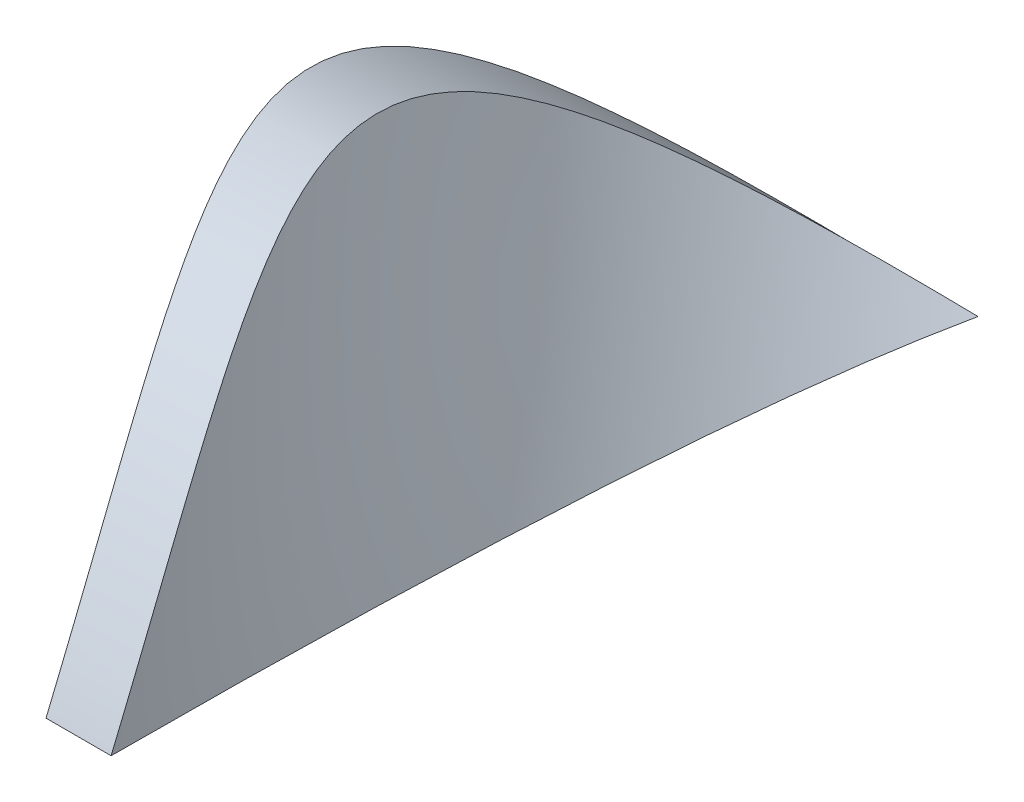
from build123d import *

# Parameters (mm, degrees)
SWEEP_1_PITCH       = 330
SWEEP_1_HEIGHT      = 60
SWEEP_1_RADIUS      = 2.5
SWEEP_1_START_ANGLE = 180
SKETCH_3_W          = 4
SKETCH_3_H          = 46
CUT_EXTRUDE_1_DEPTH = 21
CUT_EXTRUDE_2_DEPTH = 98.5


with BuildPart() as part:
    # 扫描1: sweep along a helix
    with BuildLine() as sweep_1_path:
        add(Helix(SWEEP_1_PITCH, SWEEP_1_HEIGHT, SWEEP_1_RADIUS, center=(0, 0, 0), direction=(0, 0, -1), lefthand=True, mode=Mode.PRIVATE).rotate(Axis((0, 0, 0), (0, 0, -1)), SWEEP_1_START_ANGLE))
    # 草图3 → 扫描1 (sweep)
    with BuildSketch(Plane.XY):
        with Locations((2.5, 0)):
            Rectangle(SKETCH_3_W, SKETCH_3_H)
    sweep(path=sweep_1_path.line, is_frenet=True)

    # 草图5 → 切除-拉伸1 (cut, symmetric)
    with BuildSketch(Plane(origin=(0, 0, 0), x_dir=(0, 0, -1), z_dir=(1, 0, 0))):
        with BuildLine():
            Line((50, 0), (145.717687223, 0))
            Line((145.717687223, 0), (145.717687223, 81.76666886))
            Line((145.717687223, 81.76666886), (-35.18191624, 81.76666886))
            Line((-35.18191624, 81.76666886), (-35.18191624, 0))
            Line((-35.18191624, 0), (0, 0))
            add(Edge.make_bspline(
                [(50, 0), (15.152963125, 36.372992503), (0, 0)],
                knots=[0, 0, 0, 1, 1, 1], degree=2))
        make_face()
    extrude(amount=CUT_EXTRUDE_1_DEPTH, both=True, mode=Mode.SUBTRACT)

    # 草图6 → 切除-拉伸2 (cut, symmetric)
    with BuildSketch(Plane(origin=(0, 0, 0), x_dir=(0, 0, -1), z_dir=(1, 0, 0))):
        with BuildLine():
            Line((0, 0), (71.627934589, 0))
            ThreePointArc((71.627934589, 0), (59.599015938, -39.70893354), (27.556474365, -66.067420149))
            Line((27.556474365, -66.067420149), (-48.82479627, -55.196148728))
            Line((-48.82479627, -55.196148728), (0, 0))
        make_face()
    extrude(amount=CUT_EXTRUDE_2_DEPTH, both=True, mode=Mode.SUBTRACT)


solid = part.part
